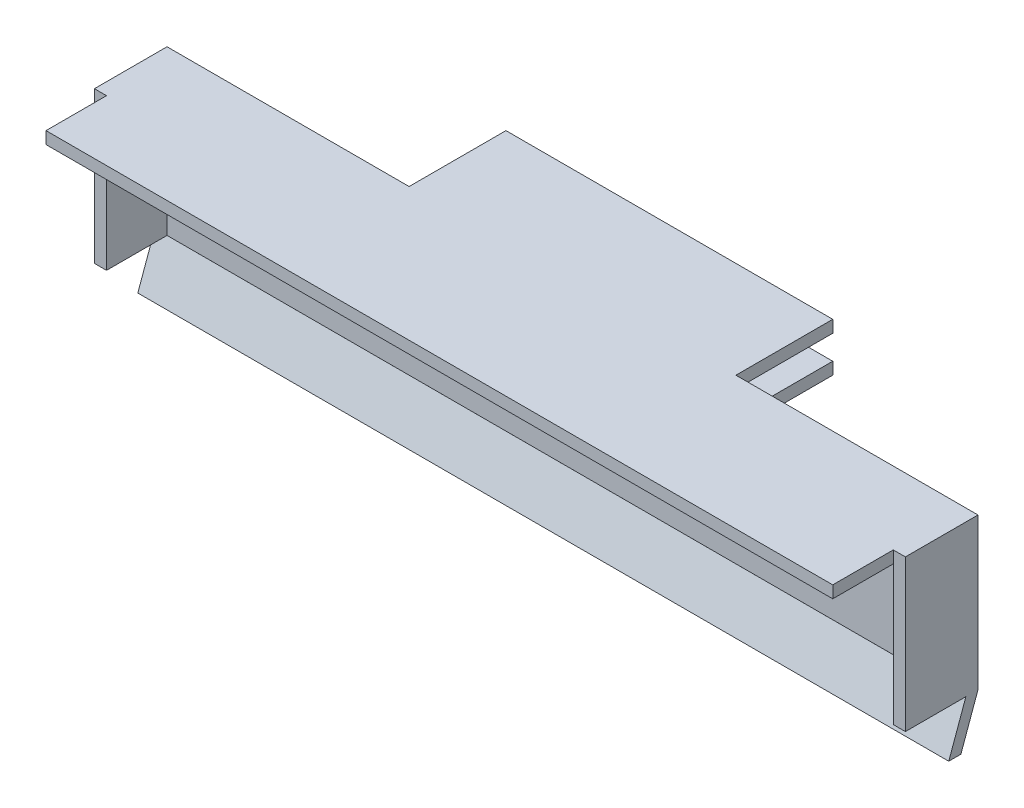
from build123d import *

# Parameters (mm, degrees)
CROQUIS1_W              = 65
CROQUIS1_H              = 10.5
SALIENTE_EXTRUIR1_DEPTH = 1
CROQUIS5_W              = 67
CROQUIS5_H              = 12.5
CROQUIS5_W_2            = 65
CROQUIS5_H_2            = 10.5
SALIENTE_EXTRUIR3_DEPTH = 6
CROQUIS6_W              = 27
CROQUIS6_H              = 1
SALIENTE_EXTRUIR4_DEPTH = 8
CROQUIS7_W              = 65
CROQUIS7_H              = 1
CORTAR_EXTRUIR1_DEPTH   = 5
SALIENTE_EXTRUIR5_DEPTH = 67
CROQUIS9_W              = 65
CROQUIS9_H              = 1
SALIENTE_EXTRUIR6_DEPTH = 5


with BuildPart() as part:
    # Croquis1 → Saliente-Extruir1 (new body)
    with BuildSketch(Plane.XY):
        with Locations((-41.330573237, 12.632352941)):
            Rectangle(CROQUIS1_W, CROQUIS1_H)
    extrude(amount=SALIENTE_EXTRUIR1_DEPTH)

    # Croquis5 → Saliente-Extruir3 (add)
    with BuildSketch(Plane(origin=(0, 0, 0), x_dir=(-1, 0, 0), z_dir=(0, 0, -1))):
        with Locations((41.330573237, 12.632352941)):
            Rectangle(CROQUIS5_W, CROQUIS5_H)
        with Locations((41.330573237, 12.632352941)):
            Rectangle(CROQUIS5_W_2, CROQUIS5_H_2, mode=Mode.SUBTRACT)
    extrude(amount=-SALIENTE_EXTRUIR3_DEPTH)

    # Croquis6 → Saliente-Extruir4 (add)
    with BuildSketch(Plane(origin=(0, 0, 0), x_dir=(-1, 0, 0), z_dir=(0, 0, -1))):
        with Locations((41.330573237, 18.382352941)):
            Rectangle(CROQUIS6_W, CROQUIS6_H)
        with Locations((41.330573237, 15.382352941)):
            Rectangle(CROQUIS6_W, CROQUIS6_H)
    extrude(amount=SALIENTE_EXTRUIR4_DEPTH)

    # Croquis7 → Cortar-Extruir1 (cut)
    with BuildSketch(Plane.XY.offset(6)):
        with Locations((-41.330573237, 6.882352941)):
            Rectangle(CROQUIS7_W, CROQUIS7_H)
    extrude(amount=-CORTAR_EXTRUIR1_DEPTH, mode=Mode.SUBTRACT)

    # Croquis8 → Saliente-Extruir5 (add)
    with BuildSketch(Plane(origin=(-7.830573237, 0, 0), x_dir=(0, 0, -1), z_dir=(1, 0, 0))):
        Polygon((0, 6.382352941), (-1.000715145, 6.382352941), (-2.414928707, 2.468139379), (-1.414213562, 2.468139379), align=None)
    extrude(amount=-SALIENTE_EXTRUIR5_DEPTH)

    # Croquis9 → Saliente-Extruir6 (add)
    with BuildSketch(Plane.XY.offset(6)):
        with Locations((-41.330573237, 18.382352941)):
            Rectangle(CROQUIS9_W, CROQUIS9_H)
    extrude(amount=SALIENTE_EXTRUIR6_DEPTH)


solid = part.part
